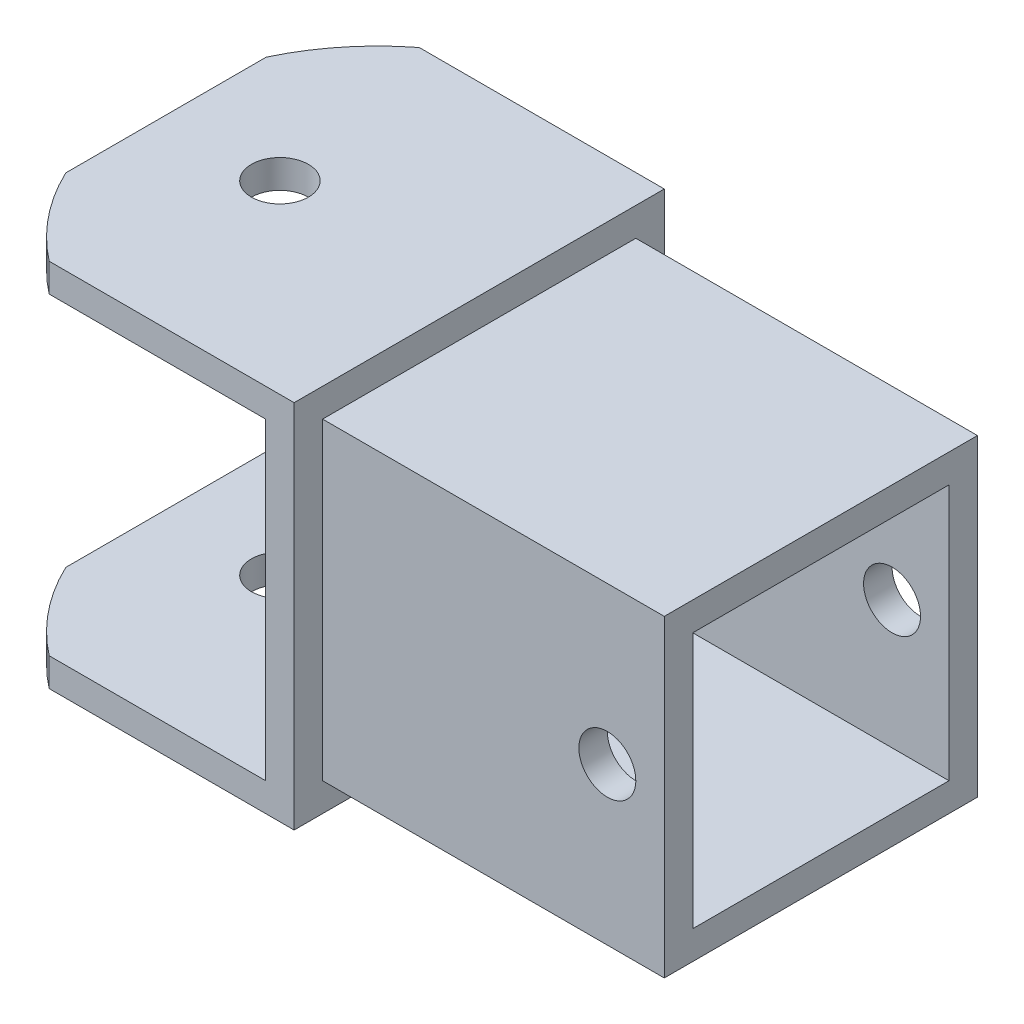
from build123d import *

# Parameters (mm, degrees)
BOSS_EXTRUDE1_DEPTH     = 82.55
SKETCH4_W               = 139.7
SKETCH4_H               = 139.7
SKETCH4_W_2             = 114.3
SKETCH4_H_2             = 114.3
BOSS_EXTRUDE2_DEPTH     = 152.4
SKETCH5_R               = 12.7
CUT_EXTRUDE1_DEPTH      = 1
CUT_EXTRUDE1_DEPTH_BACK = 166.1
SKETCH6_R               = 12.7
CUT_EXTRUDE2_DEPTH      = 13.7
CUT_EXTRUDE2_DEPTH_BACK = 153.4
CUT_EXTRUDE4_DEPTH      = 1
CUT_EXTRUDE4_DEPTH_BACK = 166.1
BODY_MOVE_COPY1_ANGLE   = 90


with BuildPart() as part:
    # Sketch2 → Boss-Extrude1 (new body, symmetric)
    with BuildSketch(Plane(origin=(0, 0, 0), x_dir=(1, 0, 0), z_dir=(0, 1, 0))):
        Polygon((-50.8, 38.1), (76.2, 38.1), (76.2, -101.6), (-50.8, -101.6), (-50.8, -114.3), (88.9, -114.3), (88.9, 50.8), (-50.8, 50.8), align=None)
    extrude(amount=BOSS_EXTRUDE1_DEPTH, both=True)

    # Sketch4 → Boss-Extrude2 (add)
    with BuildSketch(Plane(origin=(88.9, 0, 0), x_dir=(0, 0, -1), z_dir=(1, 0, 0))):
        with Locations((-31.75, 0)):
            Rectangle(SKETCH4_W, SKETCH4_H)
        with Locations((-31.75, 0)):
            Rectangle(SKETCH4_W_2, SKETCH4_H_2, mode=Mode.SUBTRACT)
    extrude(amount=BOSS_EXTRUDE2_DEPTH)

    # Sketch5 → Cut-Extrude1 (cut, two sides)
    with BuildSketch(Plane.XY.offset(114.3)) as cut_extrude1_sk:
        Circle(SKETCH5_R)
    extrude(amount=CUT_EXTRUDE1_DEPTH, mode=Mode.SUBTRACT)
    extrude(cut_extrude1_sk.sketch, amount=-CUT_EXTRUDE1_DEPTH_BACK, mode=Mode.SUBTRACT)

    # Sketch6 → Cut-Extrude2 (cut, two sides)
    with BuildSketch(Plane(origin=(0, 69.85, 0), x_dir=(1, 0, 0), z_dir=(0, 1, 0))) as cut_extrude2_sk:
        with Locations((215.9, -31.75)):
            Circle(SKETCH6_R)
    extrude(amount=CUT_EXTRUDE2_DEPTH, mode=Mode.SUBTRACT)
    extrude(cut_extrude2_sk.sketch, amount=-CUT_EXTRUDE2_DEPTH_BACK, mode=Mode.SUBTRACT)

    # Sketch7 → Cut-Extrude4 (cut, two sides)
    with BuildSketch(Plane.XY.offset(114.3)) as cut_extrude4_sk:
        with BuildLine():
            Line((-20.374273833, 82.55), (-68.429055494, 82.55))
            Line((-68.429055494, 82.55), (-68.429055494, -82.55))
            Line((-68.429055494, -82.55), (-20.374273833, -82.55))
            ThreePointArc((-20.374273833, -82.55), (-60.854450977, 0), (-20.374273833, 82.55))
        make_face()
    extrude(amount=CUT_EXTRUDE4_DEPTH, mode=Mode.SUBTRACT)
    extrude(cut_extrude4_sk.sketch, amount=-CUT_EXTRUDE4_DEPTH_BACK, mode=Mode.SUBTRACT)


with BuildPart() as part_1:
    # Body-Move/Copy1: moved
    add(part.part.rotate(Axis((0, 0, 31.75025), (1, 0, 0)), BODY_MOVE_COPY1_ANGLE))


solid = part_1.part
